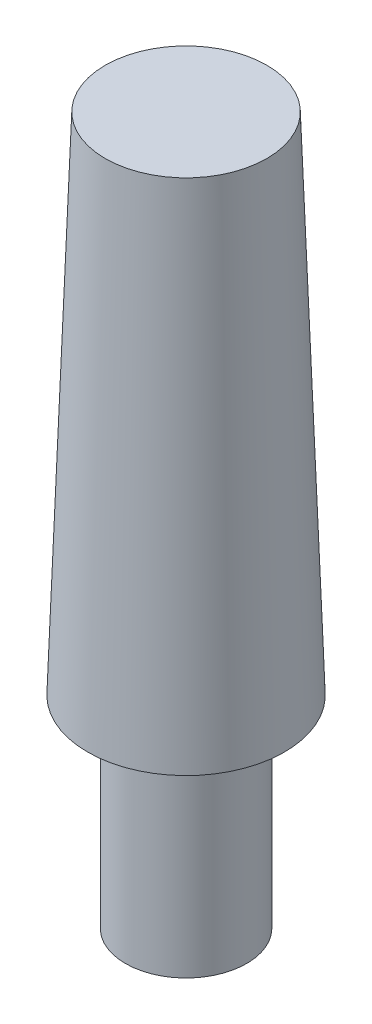
from build123d import *

# Parameters (mm, degrees)
SKETCH1_R           = 3
SKETCH1_R_2         = 1
BOSS_EXTRUDE1_DEPTH = 10
SKETCH2_R           = 4
BOSS_EXTRUDE2_DEPTH = 10
SKETCH3_R           = 4
BOSS_EXTRUDE3_DEPTH = 15
DRAFT1_ANGLE        = 2


with BuildPart() as part:
    # Sketch1 → Boss-Extrude1 (new body)
    with BuildSketch(Plane(origin=(0, 0, 0), x_dir=(1, 0, 0), z_dir=(0, 1, 0))):
        Circle(SKETCH1_R)
        Circle(SKETCH1_R_2, mode=Mode.SUBTRACT)
    extrude(amount=BOSS_EXTRUDE1_DEPTH)

    # Sketch2 → Boss-Extrude2 (add)
    with BuildSketch(Plane(origin=(0, 10, 0), x_dir=(1, 0, 0), z_dir=(0, 1, 0))):
        Circle(SKETCH2_R)
    extrude(amount=BOSS_EXTRUDE2_DEPTH)

    # Sketch3 → Boss-Extrude3 (add)
    with BuildSketch(Plane(origin=(0, 20, 0), x_dir=(1, 0, 0), z_dir=(0, 1, 0))):
        Circle(SKETCH3_R)
    extrude(amount=BOSS_EXTRUDE3_DEPTH)

    # Draft1
    draft1_faces = [part.faces().sort_by_distance(p)[0] for p in [
        (-4, 22.5, 0),
    ]]
    draft(draft1_faces, Plane.ZX.offset(35), DRAFT1_ANGLE)


solid = part.part
